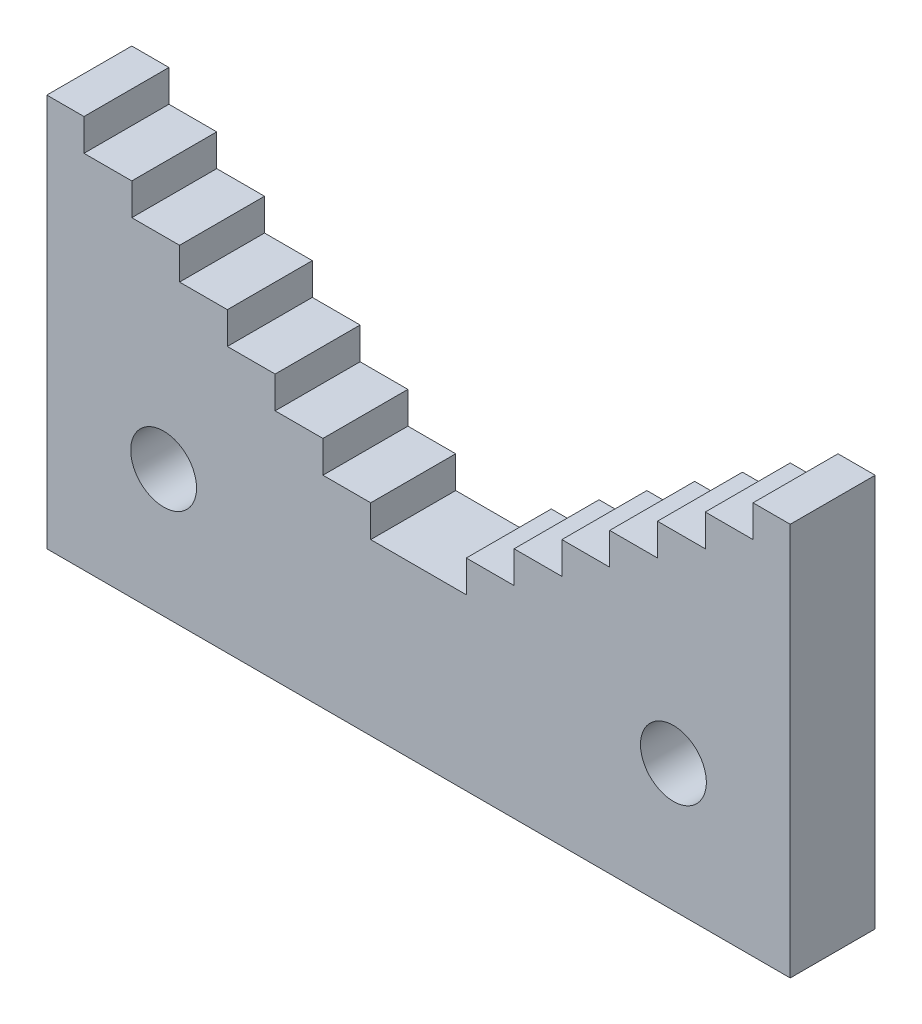
from build123d import *

# Parameters (mm, degrees)
SKETCH1_R           = 3.1
BOSS_EXTRUDE1_DEPTH = 8


with BuildPart() as part:
    # Sketch1 → Boss-Extrude1 (new body)
    with BuildSketch(Plane.XY):
        Polygon((-35, 0), (-35, 37), (-31.5, 37), (-31.5, 34), (-27, 34), (-27, 31), (-22.5, 31), (-22.5, 28), (-18, 28), (-18, 25), (-13.5, 25), (-13.5, 22), (-9, 22), (-9, 19), (-4.5, 19), (-4.5, 16), (0, 16), (0, 0), align=None)
        with Locations((-24, 12)):
            Circle(SKETCH1_R, mode=Mode.SUBTRACT)
    boss_extrude1 = extrude(amount=BOSS_EXTRUDE1_DEPTH)

    # Mirror1: Boss-Extrude1 across plane
    add(boss_extrude1.mirror(Plane(origin=(0, 0, 0), x_dir=(0, 0, 1), z_dir=(1, 0, 0))))


solid = part.part
